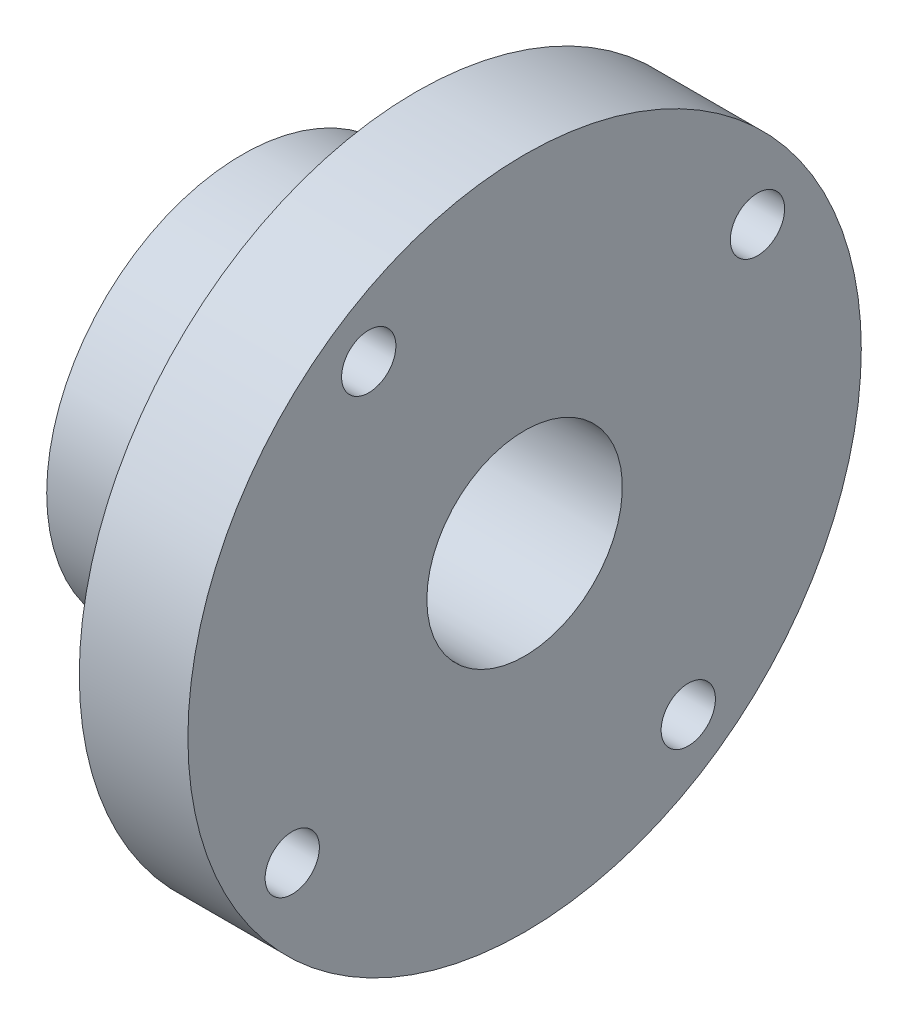
from build123d import *

# Parameters (mm, degrees)
D_GAGEMENT_M81_D                              = 9
D_GAGEMENT_M81_DEPTH                          = 13.8
TROU_POUR_TARAUDAGE_POUR_TROU_TARAUD_M4_REACH = 26.576
TROU_POUR_TARAUDAGE_POUR_TROU_TARAUD_2_R      = 1.65
TROU_POUR_TARAUDAGE_POUR_TROU_TARAUD_M3_D     = 2.5
TROU_POUR_TARAUDAGE_POUR_TROU_TARAUD_M3_DEPTH = 5


with BuildPart() as part:
    # Esquisse1 → Révolution1 (revolve)
    with BuildSketch(Plane.XY, mode=Mode.PRIVATE) as r_volution1_sk:
        Polygon((0, 0), (0, 7), (0.8, 7), (0.8, 9), (8.8, 9), (8.8, 15.5), (13.8, 15.5), (13.8, 0), align=None)
    revolve(r_volution1_sk.sketch.rotate(Axis((0, 0, 0), (1, 0, 0)), 90), axis=Axis((0, 0, 0), (1, 0, 0)))  # turned: the seam where the file's is

    # Dégagement M81
    with Locations(Plane.ZY):
        with Locations((0, 0)):
            Hole(D_GAGEMENT_M81_D / 2, depth=D_GAGEMENT_M81_DEPTH)

    # Trou pour taraudage pour trou taraud 2 (on position points) → Trou pour taraudage pour trou taraudé M4x0.71 (cut, up to next)
    with BuildSketch(Plane(origin=(4.566426523, 0.044478819, -8.99989009), x_dir=(0, -0.999987788, -0.004942091), z_dir=(0, 0.004942091, -0.999987788)), mode=Mode.PRIVATE) as trou_pour_taraudage_pour_trou_taraud_m4_sk1:
        Circle(TROU_POUR_TARAUDAGE_POUR_TROU_TARAUD_2_R)
    trou_pour_taraudage_pour_trou_taraud_m4_tool1 = extrude(trou_pour_taraudage_pour_trou_taraud_m4_sk1.sketch, amount=-TROU_POUR_TARAUDAGE_POUR_TROU_TARAUD_M4_REACH, mode=Mode.PRIVATE) & part.part
    add(trou_pour_taraudage_pour_trou_taraud_m4_tool1.solids().sort_by_distance((4.566427, 0.044479, -8.99989))[0], mode=Mode.SUBTRACT)

    # Trou pour taraudage pour trou taraudé M3x0.51
    with Locations(Plane.ZY.offset(-8.8)):
        with Locations((-10.718944801, 7.355557243), (7.174803364, 10.840765503), (10.695756801, -7.389234497), (-7.534243199, -10.594110601)):
            Hole(TROU_POUR_TARAUDAGE_POUR_TROU_TARAUD_M3_D / 2, depth=TROU_POUR_TARAUDAGE_POUR_TROU_TARAUD_M3_DEPTH)


solid = part.part
